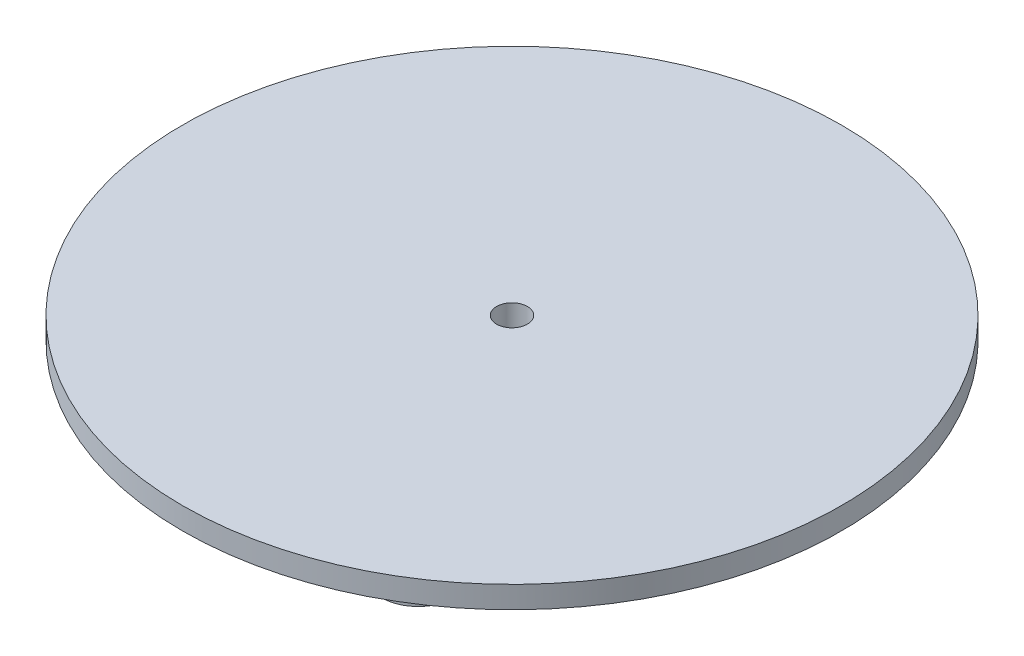
from build123d import *

# Parameters (mm, degrees)
ESQUISSE1_R             = 45
EXTRUSION1_DEPTH        = 3
ESQUISSE2_R             = 6.75
ESQUISSE2_R_2           = 3.75
ESQUISSE2_R_3           = 5
EXTRUSION2_DEPTH        = 4
ESQUISSE3_R             = 2.1
ENL_V_MAT_EXTRU_1_DEPTH = 8


with BuildPart() as part:
    # Esquisse1 → Extrusion1 (new body)
    with BuildSketch(Plane(origin=(0, 0, 0), x_dir=(1, 0, 0), z_dir=(0, 1, 0))):
        Circle(ESQUISSE1_R)
    extrude(amount=-EXTRUSION1_DEPTH)

    # Esquisse2 → Extrusion2 (add)
    with BuildSketch(Plane.XZ.offset(3)):
        Circle(ESQUISSE2_R)
        Circle(ESQUISSE2_R_2, mode=Mode.SUBTRACT)
        with Locations((-35, 0)):
            Circle(ESQUISSE2_R_3)
        with Locations((17.5, 30.310889132)):
            Circle(ESQUISSE2_R_3)
        with Locations((17.5, -30.310889132)):
            Circle(ESQUISSE2_R_3)
    extrude(amount=EXTRUSION2_DEPTH)

    # Esquisse3 → Enlèv. mat.-Extru.1 (cut, through all)
    with BuildSketch(Plane(origin=(0, 0, 0), x_dir=(1, 0, 0), z_dir=(0, 1, 0))):
        Circle(ESQUISSE3_R)
    extrude(amount=-ENL_V_MAT_EXTRU_1_DEPTH, mode=Mode.SUBTRACT)


solid = part.part
